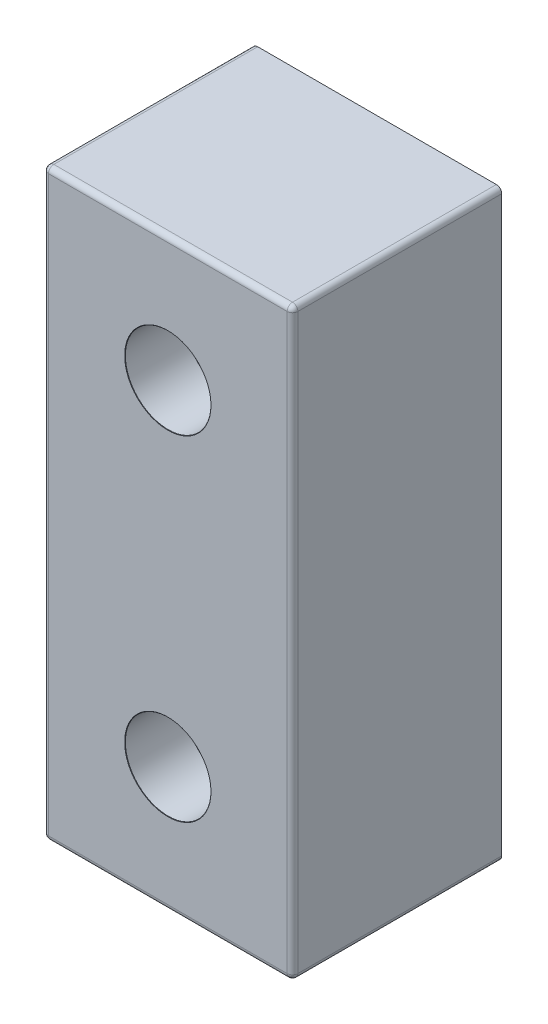
from build123d import *

# Parameters (mm, degrees)
SKETCH1_W                     = 18.923
SKETCH1_H                     = 44.323
SKETCH1_R                     = 1.5875
BOSS_EXTRUDE1_DEPTH           = 15.875
FILLET1_R                     = 0.4064
CBORE_FOR_M3_SHCS1_AT_2_COUNT = 2
CBORE_FOR_M3_SHCS1_AT_2_PITCH = 25.4


with BuildPart() as part:
    # Sketch1 → Boss-Extrude1 (new body)
    with BuildSketch(Plane.XY):
        with Locations((9.4615, 22.1615)):
            Rectangle(SKETCH1_W, SKETCH1_H)
        with Locations((9.4615, 9.4615)):
            Circle(SKETCH1_R, mode=Mode.SUBTRACT)
        with Locations((9.4615, 34.8615)):
            Circle(SKETCH1_R, mode=Mode.SUBTRACT)
    extrude(amount=BOSS_EXTRUDE1_DEPTH)

    # Fillet1
    fillet1_edges = [part.edges().sort_by_distance(p)[0] for p in [
        (0, 0, 7.9375),
        (0, 44.323, 7.9375),
        (18.923, 44.323, 7.9375),
        (18.923, 0, 7.9375),
        (7.874, 34.8615, 15.875),
        (9.4615, 0, 15.875),
        (18.923, 22.1615, 15.875),
        (9.4615, 44.323, 15.875),
        (0, 22.1615, 15.875),
        (7.874, 9.4615, 15.875),
    ]]
    fillet(fillet1_edges, radius=FILLET1_R)

    # Sketch2 → CBORE for M3 SHCS1 (revolve, cut)
    with BuildSketch(Plane(origin=(9.4615, 9.4615, 15.875), x_dir=(0, -1, 0), z_dir=(1, 0, 0))):
        Polygon((0, 0), (0, 15.875), (1.6, 15.875), (1.6, 4.5875), (3.25, 4.5875), (3.25, 0.025), (3.275, 0), align=None)
    cbore_for_m3_shcs1 = revolve(axis=Axis((9.4615, 9.4615, 22.225), (0, 0, -1)), mode=Mode.SUBTRACT)

    # CBORE for M3 SHCS1 at 2: CBORE for M3 SHCS1 ×2
    with Locations(*[(0, i * CBORE_FOR_M3_SHCS1_AT_2_PITCH, 0) for i in range(1, CBORE_FOR_M3_SHCS1_AT_2_COUNT)]):
        add(cbore_for_m3_shcs1, mode=Mode.SUBTRACT)


solid = part.part
